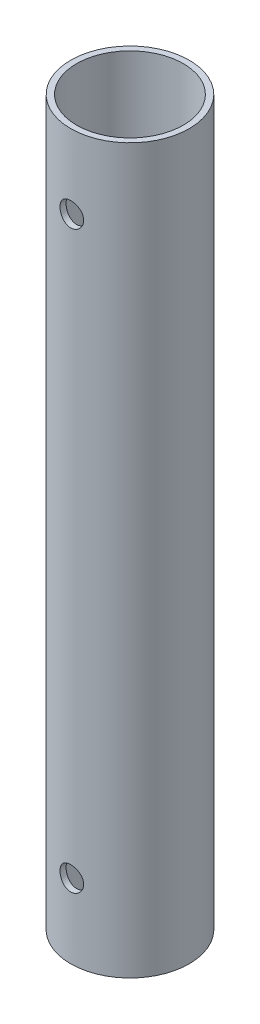
from build123d import *

# Parameters (mm, degrees)
SKETCH1_R           = 10
SKETCH1_R_2         = 9
BOSS_EXTRUDE1_DEPTH = 122
SKETCH3_R           = 2
CUT_EXTRUDE2_DEPTH  = 21


with BuildPart() as part:
    # Sketch1 → Boss-Extrude1 (new body)
    with BuildSketch(Plane(origin=(0, 0, 0), x_dir=(1, 0, 0), z_dir=(0, 1, 0))):
        Circle(SKETCH1_R)
        Circle(SKETCH1_R_2, mode=Mode.SUBTRACT)
    extrude(amount=BOSS_EXTRUDE1_DEPTH)

    # Sketch3 → Cut-Extrude2 (cut, through all)
    with BuildSketch(Plane.XY.offset(10)):
        with Locations((0, 109.5)):
            Circle(SKETCH3_R)
        with Locations((0, 12.5)):
            Circle(SKETCH3_R)
    extrude(amount=-CUT_EXTRUDE2_DEPTH, mode=Mode.SUBTRACT)


solid = part.part
